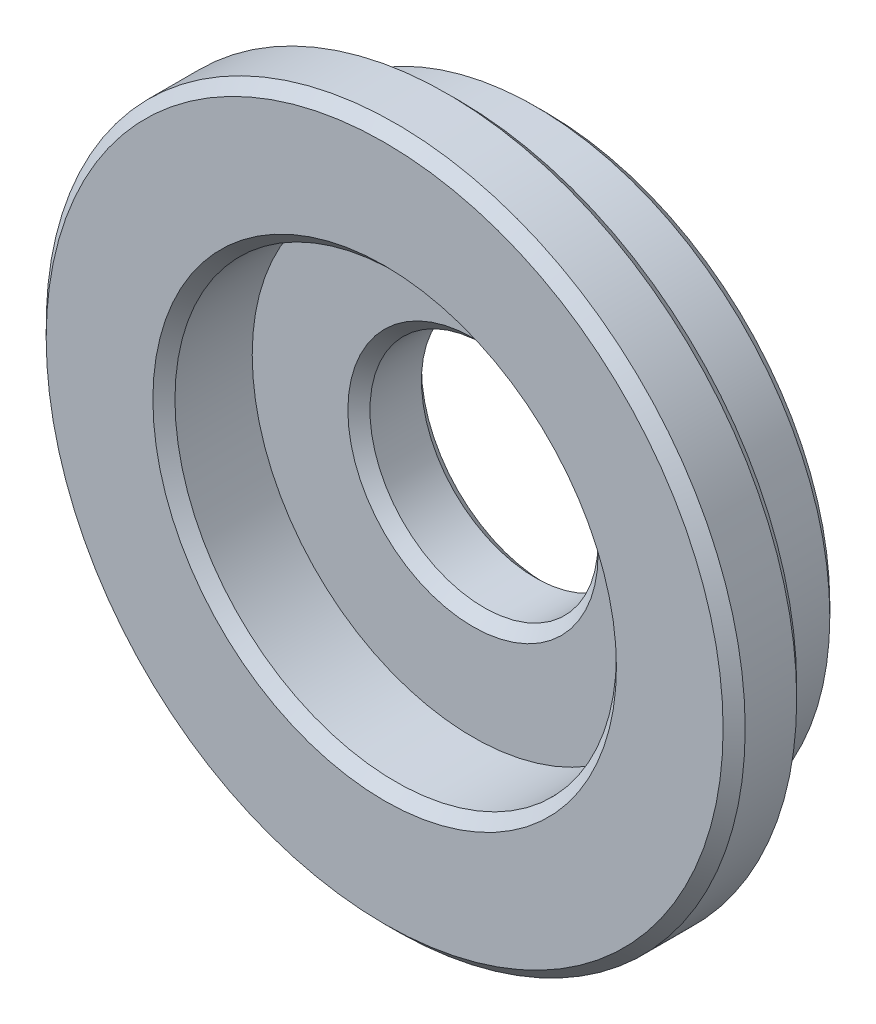
from build123d import *


with BuildPart() as part:
    # Sketch1 → Revolve1 (revolve)
    with BuildSketch(Plane(origin=(0, 0, 0), x_dir=(1, 0, 0), z_dir=(0, 1, 0))):
        Polygon((3.15, -1), (4.6, -1), (4.75, -0.85), (4.75, -0.15), (4.6, 0), (4, 0), (4, 1.05), (3.85, 1.2), (1.7, 1.2), (1.55, 1.05), (1.55, 0.35), (1.7, 0.2), (3, 0.2), (3, -0.85), align=None)
    revolve(axis=Axis((0, 0, -1.2), (0, 0, 1)))


solid = part.part
